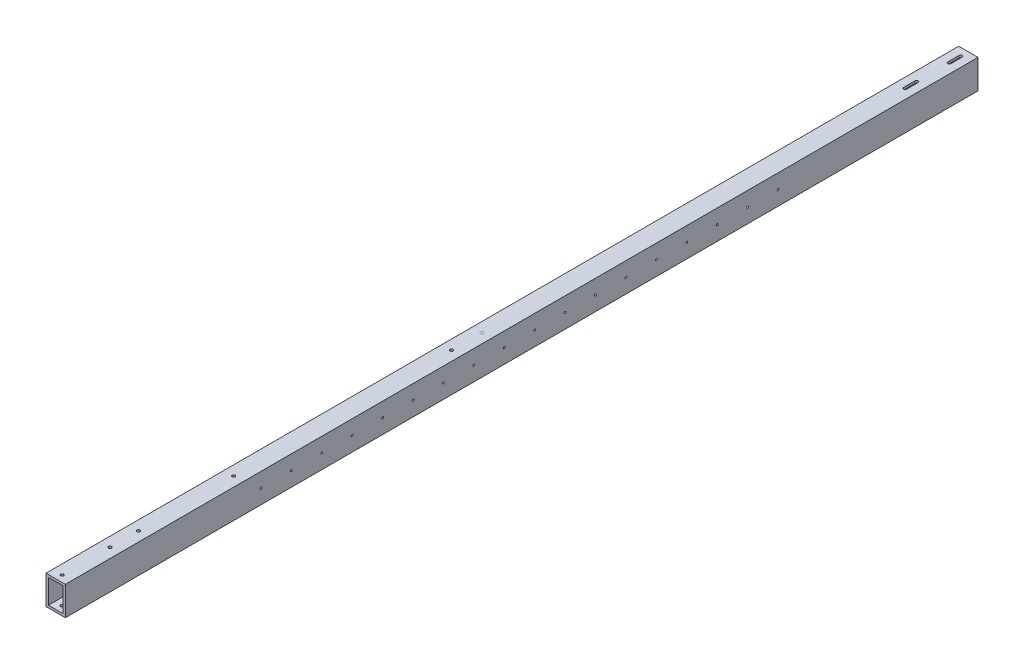
from build123d import *

# Parameters (mm, degrees)
SKETCH1_W           = 50.8
SKETCH1_H           = 76.2
SKETCH1_W_2         = 38.1
SKETCH1_H_2         = 63.5
BOSS_EXTRUDE1_DEPTH = 2400
SKETCH2_R           = 4
CUT_EXTRUDE1_DEPTH  = 77.2
SKETCH3_R           = 2.5
CUT_EXTRUDE2_DEPTH  = 2438.4
SKETCH4_R           = 3.95
CUT_EXTRUDE3_DEPTH  = 77.2
SKETCH5_R           = 4
SKETCH5_R_2         = 3.95
CUT_EXTRUDE4_DEPTH  = 77.2


with BuildPart() as part:
    # Sketch1 → Boss-Extrude1 (new body)
    with BuildSketch(Plane.XY):
        Rectangle(SKETCH1_W, SKETCH1_H)
        Rectangle(SKETCH1_W_2, SKETCH1_H_2, mode=Mode.SUBTRACT)
    extrude(amount=BOSS_EXTRUDE1_DEPTH)

    # Sketch2 → Cut-Extrude1 (cut, through all)
    with BuildSketch(Plane(origin=(0, 38.1, 0), x_dir=(1, 0, 0), z_dir=(0, 1, 0))):
        with Locations((0, -2383)):
            Circle(SKETCH2_R)
        with Locations((0, -2257)):
            Circle(SKETCH2_R)
        with BuildLine():
            Line((4, -136), (4, -166))
            ThreePointArc((4, -166), (0, -170), (-4, -166))
            Line((-4, -166), (-4, -136))
            ThreePointArc((-4, -136), (0, -132), (4, -136))
        make_face()
        with BuildLine():
            Line((3.997827358, -20), (3.997827358, -50))
            ThreePointArc((3.997827358, -50), (0, -53.997827358), (-3.997827358, -50))
            Line((-3.997827358, -50), (-3.997827358, -20))
            ThreePointArc((-3.997827358, -20), (0, -16.002172642), (3.997827358, -20))
        make_face()
    extrude(amount=-CUT_EXTRUDE1_DEPTH, mode=Mode.SUBTRACT)

    # Sketch3 → Cut-Extrude2 (cut)
    with BuildSketch(Plane(origin=(25.4, 0, 0), x_dir=(0, 0, -1), z_dir=(1, 0, 0))):
        with Locations((-1885.8, 0)):
            Circle(SKETCH3_R)
        with Locations((-1805.8, 0)):
            Circle(SKETCH3_R)
        with Locations((-1725.8, 0)):
            Circle(SKETCH3_R)
        with Locations((-1645.8, 0)):
            Circle(SKETCH3_R)
        with Locations((-1565.8, 0)):
            Circle(SKETCH3_R)
        with Locations((-1485.8, 0)):
            Circle(SKETCH3_R)
        with Locations((-1405.8, 0)):
            Circle(SKETCH3_R)
        with Locations((-1325.8, 0)):
            Circle(SKETCH3_R)
        with Locations((-1245.8, 0)):
            Circle(SKETCH3_R)
        with Locations((-1165.8, 0)):
            Circle(SKETCH3_R)
        with Locations((-1085.8, 0)):
            Circle(SKETCH3_R)
        with Locations((-1005.8, 0)):
            Circle(SKETCH3_R)
        with Locations((-925.8, 0)):
            Circle(SKETCH3_R)
        with Locations((-845.8, 0)):
            Circle(SKETCH3_R)
        with Locations((-765.8, 0)):
            Circle(SKETCH3_R)
        with Locations((-685.8, 0)):
            Circle(SKETCH3_R)
        with Locations((-605.8, 0)):
            Circle(SKETCH3_R)
        with Locations((-525.8, 0)):
            Circle(SKETCH3_R)
    extrude(amount=-CUT_EXTRUDE2_DEPTH, mode=Mode.SUBTRACT)

    # Sketch4 → Cut-Extrude3 (cut, through all)
    with BuildSketch(Plane(origin=(0, 38.1, 0), x_dir=(1, 0, 0), z_dir=(0, 1, 0))):
        with Locations((0, -2182)):
            Circle(SKETCH4_R)
        with Locations((0, -1932)):
            Circle(SKETCH4_R)
    extrude(amount=-CUT_EXTRUDE3_DEPTH, mode=Mode.SUBTRACT)

    # Sketch5 → Cut-Extrude4 (cut, through all)
    with BuildSketch(Plane(origin=(0, 38.1, 0), x_dir=(1, 0, 0), z_dir=(0, 1, 0))):
        with Locations((0, -1359)):
            Circle(SKETCH5_R)
        with Locations((0, -1279)):
            Circle(SKETCH5_R)
        with Locations((0, -1278.999999999)):
            Circle(SKETCH5_R_2, mode=Mode.SUBTRACT)
        with BuildLine():
            Line((-109.6, -1300.1), (-99.6, -1300.1))
            ThreePointArc((-99.6, -1300.1), (-94.1, -1294.6), (-99.6, -1289.1))
            Line((-99.6, -1289.1), (-109.6, -1289.1))
            ThreePointArc((-109.6, -1289.1), (-115.1, -1294.6), (-109.6, -1300.1))
        make_face()
    extrude(amount=-CUT_EXTRUDE4_DEPTH, mode=Mode.SUBTRACT)


solid = part.part
